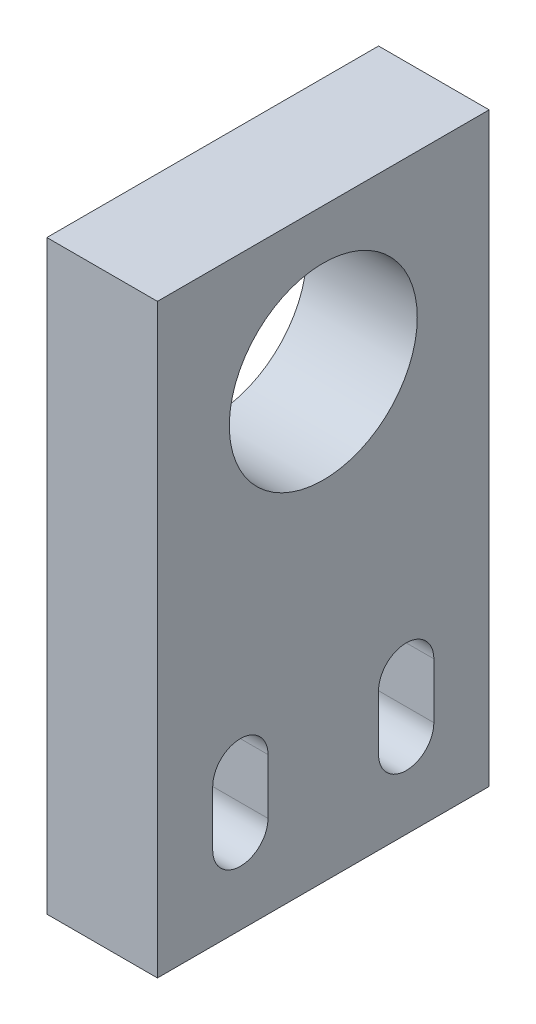
from build123d import *

# Parameters (mm, degrees)
SKETCH1_W           = 30
SKETCH1_H           = 53
SKETCH1_R           = 8.5
BOSS_EXTRUDE1_DEPTH = 10


with BuildPart() as part:
    # Sketch1 → Boss-Extrude1 (new body)
    with BuildSketch(Plane(origin=(0, 0, 0), x_dir=(0, 0, -1), z_dir=(1, 0, 0))):
        with Locations((0, -13.5)):
            Rectangle(SKETCH1_W, SKETCH1_H)
        Circle(SKETCH1_R, mode=Mode.SUBTRACT)
        with BuildLine():
            Line((-5, -27.5), (-5, -32.5))
            ThreePointArc((-5, -32.5), (-7.5, -35), (-10, -32.5))
            Line((-10, -32.5), (-10, -27.5))
            ThreePointArc((-10, -27.5), (-7.5, -25), (-5, -27.5))
        make_face(mode=Mode.SUBTRACT)
        with BuildLine():
            Line((5, -27.5), (5, -32.5))
            ThreePointArc((5, -32.5), (7.5, -35), (10, -32.5))
            Line((10, -32.5), (10, -27.5))
            ThreePointArc((10, -27.5), (7.5, -25), (5, -27.5))
        make_face(mode=Mode.SUBTRACT)
    extrude(amount=BOSS_EXTRUDE1_DEPTH)


solid = part.part
